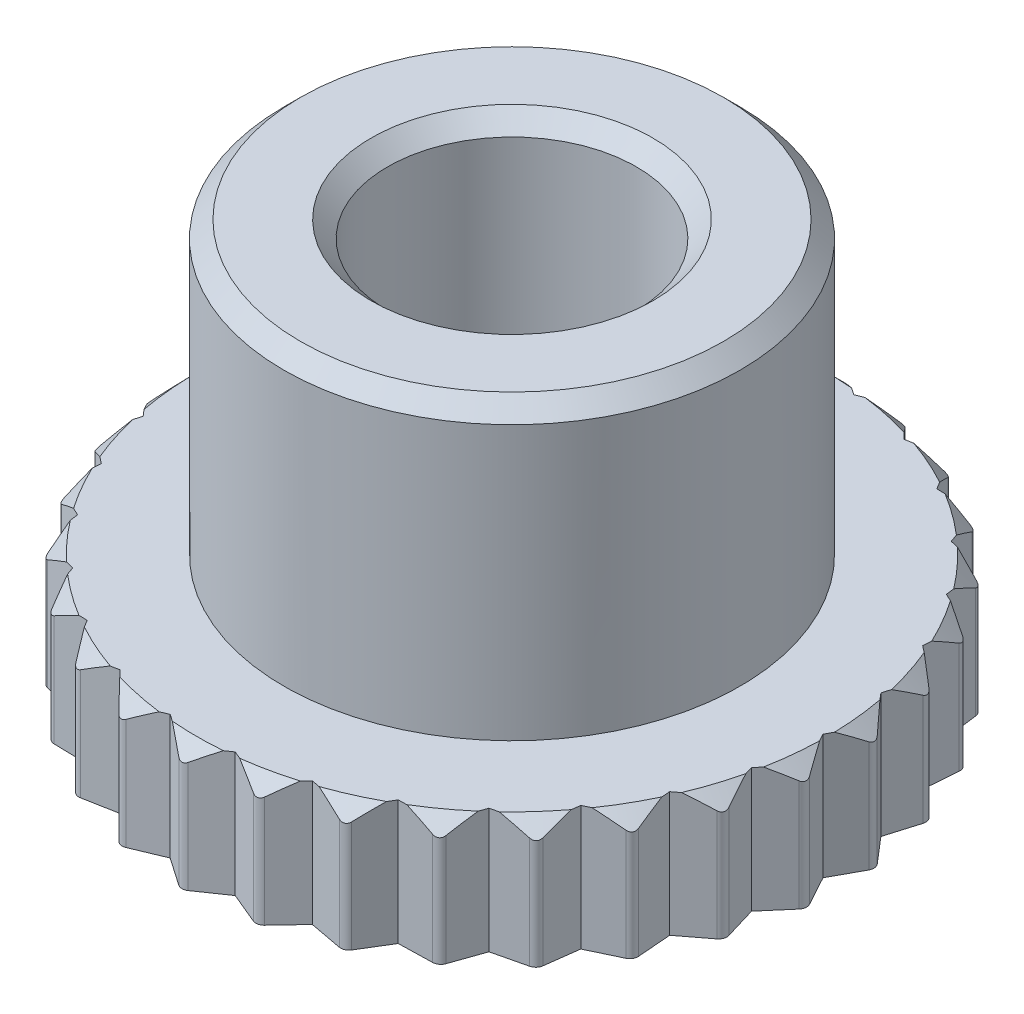
from build123d import *

# Parameters (mm, degrees)
SKIZZE9_R                       = 3
SCHNITT_LINEAR_AUSTRAGEN3_DEPTH = 11
FASE1_SIZE                      = 0.4
FASE2_SIZE                      = 0.4
SCHNITT_LINEAR_AUSTRAGEN1_DEPTH = 11
VERRUNDUNG1_R                   = 0.2


with BuildPart() as part:
    # Skizze1 → Rotation1 (revolve)
    with BuildSketch(Plane.XY, mode=Mode.PRIVATE) as rotation1_sk:
        Polygon((0, 0), (8, 0), (8, 3), (5.5, 3), (5.5, 10), (0, 10), align=None)
    revolve(rotation1_sk.sketch.rotate(Axis((0, 10, 0), (0, -1, 0)), 180), axis=Axis((0, 10, 0), (0, -1, 0)))  # turned: the seam where the file's is

    # Skizze9 → Schnitt-Linear austragen3 (cut, through all)
    with BuildSketch(Plane.XZ):
        Circle(SKIZZE9_R)
    extrude(amount=-SCHNITT_LINEAR_AUSTRAGEN3_DEPTH, mode=Mode.SUBTRACT)

    # Fase1
    fase1_edges = [part.edges().sort_by_distance(p)[0] for p in [
        (-3, 10, 0),
        (5.5, 10, 0),
    ]]
    chamfer(fase1_edges, length=FASE1_SIZE)

    # Fase2
    fase2_edges = [part.edges().sort_by_distance(p)[0] for p in [
        (8, 3, 0),
    ]]
    chamfer(fase2_edges, length=FASE2_SIZE)

    # Skizze8 → Schnitt-Linear austragen1 (cut, through all)
    with BuildSketch(Plane.XZ):
        with BuildLine():
            ThreePointArc((1.663293527, 7.825180806), (0.836227706, 7.956175163), (0, 8))
            Line((0, 8), (0.783963475, 7.458914215))
            Line((0.783963475, 7.458914215), (1.663293527, 7.825180806))
        make_face()
        with BuildLine():
            ThreePointArc((3.253893145, 7.308363661), (2.472135955, 7.60845213), (1.663293527, 7.825180806))
            Line((1.663293527, 7.825180806), (2.317627458, 7.132923872))
            Line((2.317627458, 7.132923872), (3.253893145, 7.308363661))
        make_face()
        with BuildLine():
            ThreePointArc((4.702282018, 6.472135955), (4, 6.92820323), (3.253893145, 7.308363661))
            Line((3.253893145, 7.308363661), (3.75, 6.495190528))
            Line((3.75, 6.495190528), (4.702282018, 6.472135955))
        make_face()
        with BuildLine():
            ThreePointArc((5.945158604, 5.353044851), (5.353044851, 5.945158604), (4.702282018, 6.472135955))
            Line((4.702282018, 6.472135955), (5.018479548, 5.573586191))
            Line((5.018479548, 5.573586191), (5.945158604, 5.353044851))
        make_face()
        with BuildLine():
            ThreePointArc((7.60845213, 2.472135955), (7.308363661, 3.253893145), (6.92820323, 4))
            Line((6.92820323, 4), (6.851590932, 3.050524823))
            Line((6.851590932, 3.050524823), (7.60845213, 2.472135955))
        make_face()
        with BuildLine():
            ThreePointArc((7.956175163, 0.836227706), (7.825180806, 1.663293527), (7.60845213, 2.472135955))
            Line((7.60845213, 2.472135955), (7.336107006, 1.559337681))
            Line((7.336107006, 1.559337681), (7.956175163, 0.836227706))
        make_face()
        with BuildLine():
            ThreePointArc((8, 0), (7.989036278, 0.41868765), (7.956175163, 0.836227706))
            Line((7.956175163, 0.836227706), (7.5, 0))
            Line((7.5, 0), (7.956175163, -0.836227706))
            ThreePointArc((7.956175163, -0.836227706), (7.989036278, -0.41868765), (8, 0))
        make_face()
        with BuildLine():
            ThreePointArc((6.92820323, -4), (7.308363661, -3.253893145), (7.60845213, -2.472135955))
            Line((7.60845213, -2.472135955), (6.851590932, -3.050524823))
            Line((6.851590932, -3.050524823), (6.92820323, -4))
        make_face()
        with BuildLine():
            ThreePointArc((5.945158604, -5.353044851), (6.472135955, -4.702282018), (6.92820323, -4))
            Line((6.92820323, -4), (6.067627458, -4.408389392))
            Line((6.067627458, -4.408389392), (5.945158604, -5.353044851))
        make_face()
        with BuildLine():
            ThreePointArc((3.253893145, -7.308363661), (4, -6.92820323), (4.702282018, -6.472135955))
            Line((4.702282018, -6.472135955), (3.75, -6.495190528))
            Line((3.75, -6.495190528), (3.253893145, -7.308363661))
        make_face()
        with BuildLine():
            ThreePointArc((1.663293527, -7.825180806), (2.472135955, -7.60845213), (3.253893145, -7.308363661))
            Line((3.253893145, -7.308363661), (2.317627458, -7.132923872))
            Line((2.317627458, -7.132923872), (1.663293527, -7.825180806))
        make_face()
        with BuildLine():
            ThreePointArc((0, -8), (0.836227706, -7.956175163), (1.663293527, -7.825180806))
            Line((1.663293527, -7.825180806), (0.783963475, -7.458914215))
            Line((0.783963475, -7.458914215), (0, -8))
        make_face()
        with BuildLine():
            Line((-0.783963475, -7.458914215), (-1.663293527, -7.825180806))
            ThreePointArc((-1.663293527, -7.825180806), (-0.836227706, -7.956175163), (0, -8))
            Line((0, -8), (-0.783963475, -7.458914215))
        make_face()
        with BuildLine():
            Line((-2.317627458, -7.132923872), (-3.253893145, -7.308363661))
            ThreePointArc((-3.253893145, -7.308363661), (-2.472135955, -7.60845213), (-1.663293527, -7.825180806))
            Line((-1.663293527, -7.825180806), (-2.317627458, -7.132923872))
        make_face()
        with BuildLine():
            Line((-3.75, -6.495190528), (-4.702282018, -6.472135955))
            ThreePointArc((-4.702282018, -6.472135955), (-4, -6.92820323), (-3.253893145, -7.308363661))
            Line((-3.253893145, -7.308363661), (-3.75, -6.495190528))
        make_face()
        with BuildLine():
            Line((-5.018479548, -5.573586191), (-5.945158604, -5.353044851))
            ThreePointArc((-5.945158604, -5.353044851), (-5.353044851, -5.945158604), (-4.702282018, -6.472135955))
            Line((-4.702282018, -6.472135955), (-5.018479548, -5.573586191))
        make_face()
        with BuildLine():
            Line((-6.067627458, -4.408389392), (-6.92820323, -4))
            ThreePointArc((-6.92820323, -4), (-6.472135955, -4.702282018), (-5.945158604, -5.353044851))
            Line((-5.945158604, -5.353044851), (-6.067627458, -4.408389392))
        make_face()
        with BuildLine():
            Line((-6.851590932, -3.050524823), (-7.60845213, -2.472135955))
            ThreePointArc((-7.60845213, -2.472135955), (-7.308363661, -3.253893145), (-6.92820323, -4))
            Line((-6.92820323, -4), (-6.851590932, -3.050524823))
        make_face()
        with BuildLine():
            Line((-7.336107006, -1.559337681), (-7.956175163, -0.836227706))
            ThreePointArc((-7.956175163, -0.836227706), (-7.825180806, -1.663293527), (-7.60845213, -2.472135955))
            Line((-7.60845213, -2.472135955), (-7.336107006, -1.559337681))
        make_face()
        with BuildLine():
            Line((-7.5, 0), (-7.956175163, 0.836227706))
            ThreePointArc((-7.956175163, 0.836227706), (-8, 0), (-7.956175163, -0.836227706))
            Line((-7.956175163, -0.836227706), (-7.5, 0))
        make_face()
        with BuildLine():
            Line((-7.336107006, 1.559337681), (-7.60845213, 2.472135955))
            ThreePointArc((-7.60845213, 2.472135955), (-7.825180806, 1.663293527), (-7.956175163, 0.836227706))
            Line((-7.956175163, 0.836227706), (-7.336107006, 1.559337681))
        make_face()
        with BuildLine():
            Line((-6.851590932, 3.050524823), (-6.92820323, 4))
            ThreePointArc((-6.92820323, 4), (-7.308363661, 3.253893145), (-7.60845213, 2.472135955))
            Line((-7.60845213, 2.472135955), (-6.851590932, 3.050524823))
        make_face()
        with BuildLine():
            Line((-6.067627458, 4.408389392), (-5.945158604, 5.353044851))
            ThreePointArc((-5.945158604, 5.353044851), (-6.472135955, 4.702282018), (-6.92820323, 4))
            Line((-6.92820323, 4), (-6.067627458, 4.408389392))
        make_face()
        with BuildLine():
            Line((-5.018479548, 5.573586191), (-4.702282018, 6.472135955))
            ThreePointArc((-4.702282018, 6.472135955), (-5.353044851, 5.945158604), (-5.945158604, 5.353044851))
            Line((-5.945158604, 5.353044851), (-5.018479548, 5.573586191))
        make_face()
        with BuildLine():
            Line((-3.75, 6.495190528), (-3.253893145, 7.308363661))
            ThreePointArc((-3.253893145, 7.308363661), (-4, 6.92820323), (-4.702282018, 6.472135955))
            Line((-4.702282018, 6.472135955), (-3.75, 6.495190528))
        make_face()
        with BuildLine():
            Line((-2.317627458, 7.132923872), (-1.663293527, 7.825180806))
            ThreePointArc((-1.663293527, 7.825180806), (-2.472135955, 7.60845213), (-3.253893145, 7.308363661))
            Line((-3.253893145, 7.308363661), (-2.317627458, 7.132923872))
        make_face()
        with BuildLine():
            Line((-0.783963475, 7.458914215), (0, 8))
            ThreePointArc((0, 8), (-0.836227706, 7.956175163), (-1.663293527, 7.825180806))
            Line((-1.663293527, 7.825180806), (-0.783963475, 7.458914215))
        make_face()
        with BuildLine():
            ThreePointArc((6.92820323, 4), (6.472135955, 4.702282018), (5.945158604, 5.353044851))
            Line((5.945158604, 5.353044851), (6.067627458, 4.408389392))
            Line((6.067627458, 4.408389392), (6.92820323, 4))
        make_face()
        with BuildLine():
            ThreePointArc((7.60845213, -2.472135955), (7.825180806, -1.663293527), (7.956175163, -0.836227706))
            Line((7.956175163, -0.836227706), (7.336107006, -1.559337681))
            Line((7.336107006, -1.559337681), (7.60845213, -2.472135955))
        make_face()
        with BuildLine():
            Line((5.945158604, -5.353044851), (5.018479548, -5.573586191))
            Line((5.018479548, -5.573586191), (4.702282018, -6.472135955))
            ThreePointArc((4.702282018, -6.472135955), (5.353044851, -5.945158604), (5.945158604, -5.353044851))
        make_face()
    extrude(amount=-SCHNITT_LINEAR_AUSTRAGEN1_DEPTH, mode=Mode.SUBTRACT)

    # Verrundung1
    verrundung1_edges = [part.edges().sort_by_distance(p)[0] for p in [
        (0, 1.3, 8),
        (-1.663293527, 1.3, 7.825180806),
        (-3.253893145, 1.3, 7.308363661),
        (-4.702282018, 1.3, 6.472135955),
        (-5.945158604, 1.3, 5.353044851),
        (-6.92820323, 1.3, 4),
        (-7.60845213, 1.3, 2.472135955),
        (-7.956175163, 1.3, 0.836227706),
        (-7.956175163, 1.3, -0.836227706),
        (-7.60845213, 1.3, -2.472135955),
        (-5.945158604, 1.3, -5.353044851),
        (-6.92820323, 1.3, -4),
        (-4.702282018, 1.3, -6.472135955),
        (-3.253893145, 1.3, -7.308363661),
        (-1.663293527, 1.3, -7.825180806),
        (0, 1.3, -8),
        (1.663293527, 1.3, -7.825180806),
        (3.253893145, 1.3, -7.308363661),
        (4.702282018, 1.3, -6.472135955),
        (5.945158604, 1.3, -5.353044851),
        (6.92820323, 1.3, -4),
        (7.60845213, 1.3, -2.472135955),
        (7.956175163, 1.3, -0.836227706),
        (7.956175163, 1.3, 0.836227706),
        (7.60845213, 1.3, 2.472135955),
        (6.92820323, 1.3, 4),
        (5.945158604, 1.3, 5.353044851),
        (4.702282018, 1.3, 6.472135955),
        (3.253893145, 1.3, 7.308363661),
        (1.663293527, 1.3, 7.825180806),
    ]]
    fillet(verrundung1_edges, radius=VERRUNDUNG1_R)


solid = part.part
